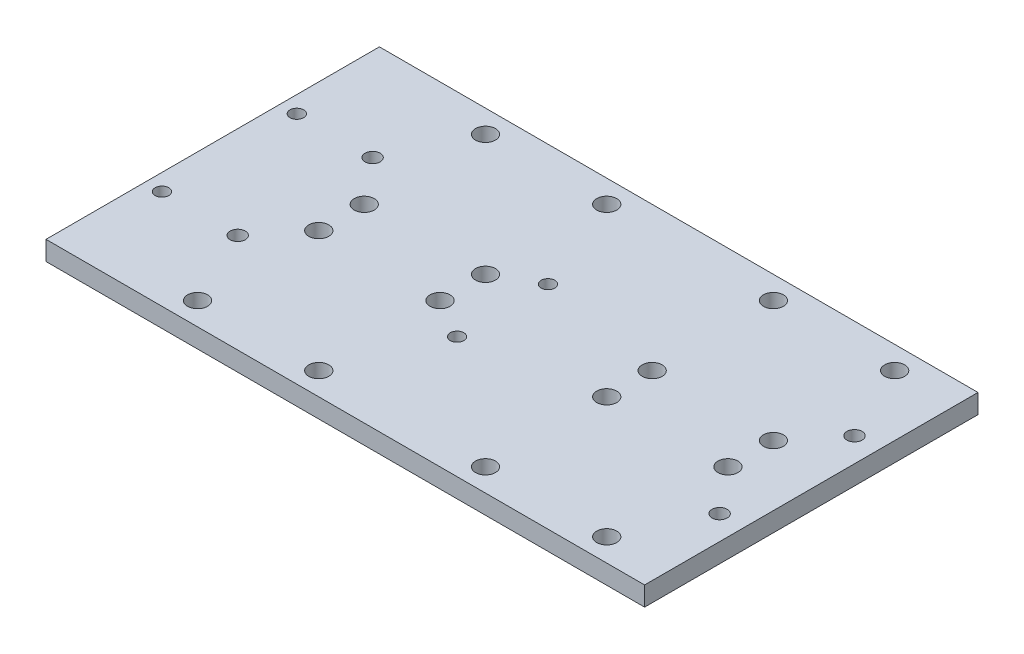
from build123d import *

# Parameters (mm, degrees)
SKETCH1_W                 = 200
SKETCH1_H                 = 110
BOSS_EXTRUDE1_DEPTH       = 6.35
M6_CLEARANCE_HOLE1_D      = 6.6
M6_CLEARANCE_HOLE1_DEPTH  = 12.4
M6_CLEARANCE_HOLE1_TIP    = 1.982840043
EXTENDO_W                 = 10
EXTENDO_H                 = 110
BOSS_EXTRUDE2_DEPTH       = 6.35
M6X1_0_TAPPED_HOLE2_D     = 5
M6X1_0_TAPPED_HOLE2_DEPTH = 15
M6X1_0_TAPPED_HOLE2_TIP   = 1.502151548
M4_CLEARANCE_HOLE2_D      = 4.5
M4_CLEARANCE_HOLE2_DEPTH  = 15
M4_CLEARANCE_HOLE2_TIP    = 1.351936393
M4_CLEARANCE_HOLE3_D      = 4.5
M4_CLEARANCE_HOLE3_DEPTH  = 15
M4_CLEARANCE_HOLE3_TIP    = 1.351936393
SKETCH20_W                = 12.5
SKETCH20_H                = 110
CUT_EXTRUDE1_DEPTH        = 6.35


with BuildPart() as part:
    # Sketch1 → Boss-Extrude1 (new body)
    with BuildSketch(Plane(origin=(0, 0, 0), x_dir=(1, 0, 0), z_dir=(0, 1, 0))):
        Rectangle(SKETCH1_W, SKETCH1_H)
    extrude(amount=BOSS_EXTRUDE1_DEPTH)

    # M6 Clearance Hole1
    with Locations(Plane(origin=(-67.5, 6.35, -47.5), x_dir=(0, 0, 1), z_dir=(0, 1, 0))):
        with Locations((0, 0), (0, 40), (40, 40), (40, 0), (55, 0), (55, 40), (95, 40), (95, 0), (95, 95), (55, 95), (40, 95), (0, 95), (0, 135), (40, 135), (55, 135), (95, 135)):
            Hole(M6_CLEARANCE_HOLE1_D / 2, depth=M6_CLEARANCE_HOLE1_DEPTH)
            with Locations((0, 0, -(M6_CLEARANCE_HOLE1_DEPTH + M6_CLEARANCE_HOLE1_TIP / 2))):  # 118° drill point
                Cone(0, M6_CLEARANCE_HOLE1_D / 2, M6_CLEARANCE_HOLE1_TIP, mode=Mode.SUBTRACT)

    # Extendo → Boss-Extrude2 (add)
    with BuildSketch(Plane(origin=(0, 6.35, 0), x_dir=(1, 0, 0), z_dir=(0, 1, 0))):
        with Locations((-105, 0)):
            Rectangle(EXTENDO_W, EXTENDO_H)
    extrude(amount=-BOSS_EXTRUDE2_DEPTH)

    # M6x1.0 Tapped Hole2
    with Locations(Plane(origin=(-79.5, 6.35, -22.25), x_dir=(0, 0, 1), z_dir=(0, 1, 0))):
        with Locations((0, 0), (44.5, 0), (44.5, 159), (0, 159)):
            Hole(M6X1_0_TAPPED_HOLE2_D / 2, depth=M6X1_0_TAPPED_HOLE2_DEPTH)
            with Locations((0, 0, -(M6X1_0_TAPPED_HOLE2_DEPTH + M6X1_0_TAPPED_HOLE2_TIP / 2))):  # 118° drill point
                Cone(0, M6X1_0_TAPPED_HOLE2_D / 2, M6X1_0_TAPPED_HOLE2_TIP, mode=Mode.SUBTRACT)

    # M4 Clearance Hole2
    with Locations(Plane(origin=(-104.5, 6.35, -22.25), x_dir=(0, 0, 1), z_dir=(0, 1, 0))):
        with Locations((0, 0), (44.5, 0)):
            Hole(M4_CLEARANCE_HOLE2_D / 2, depth=M4_CLEARANCE_HOLE2_DEPTH)
            with Locations((0, 0, -(M4_CLEARANCE_HOLE2_DEPTH + M4_CLEARANCE_HOLE2_TIP / 2))):  # 118° drill point
                Cone(0, M4_CLEARANCE_HOLE2_D / 2, M4_CLEARANCE_HOLE2_TIP, mode=Mode.SUBTRACT)

    # M4 Clearance Hole3
    with Locations(Plane(origin=(-14.375, 6.35, -15), x_dir=(0, 0, 1), z_dir=(0, 1, 0))):
        with Locations((0, 0), (30, 0)):
            Hole(M4_CLEARANCE_HOLE3_D / 2, depth=M4_CLEARANCE_HOLE3_DEPTH)
            with Locations((0, 0, -(M4_CLEARANCE_HOLE3_DEPTH + M4_CLEARANCE_HOLE3_TIP / 2))):  # 118° drill point
                Cone(0, M4_CLEARANCE_HOLE3_D / 2, M4_CLEARANCE_HOLE3_TIP, mode=Mode.SUBTRACT)

    # Sketch20 → Cut-Extrude1 (cut)
    with BuildSketch(Plane(origin=(0, 6.35, 0), x_dir=(1, 0, 0), z_dir=(0, 1, 0))):
        with Locations((93.75, 0)):
            Rectangle(SKETCH20_W, SKETCH20_H)
    extrude(amount=-CUT_EXTRUDE1_DEPTH, mode=Mode.SUBTRACT)


solid = part.part
